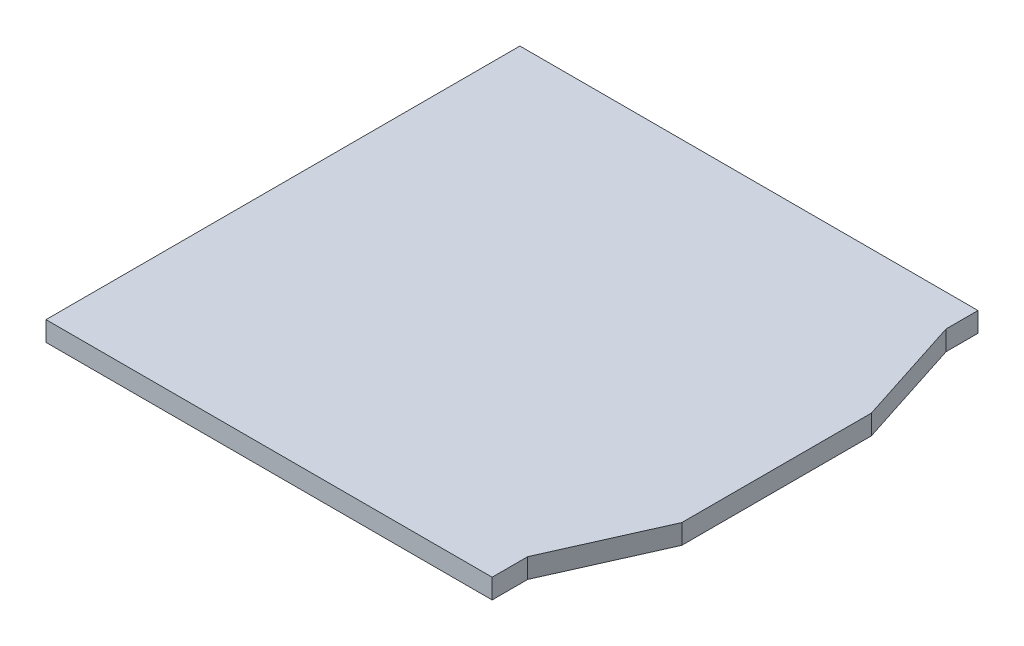
from build123d import *

# Parameters (mm, degrees)
BOSS_EXTRUDE1_DEPTH = 0.25


with BuildPart() as part:
    # Sketch1 → Boss-Extrude1 (new body)
    with BuildSketch(Plane(origin=(0, 0, 0), x_dir=(1, 0, 0), z_dir=(0, 1, 0))):
        Polygon((2.675, 3), (2.675, 2.595673931), (3.125, 1.2), (3.125, -1.2), (2.523466161, -2.55), (2.523466161, -3), (-3.125, -3), (-3.125, 3), align=None)
    extrude(amount=BOSS_EXTRUDE1_DEPTH)


solid = part.part
